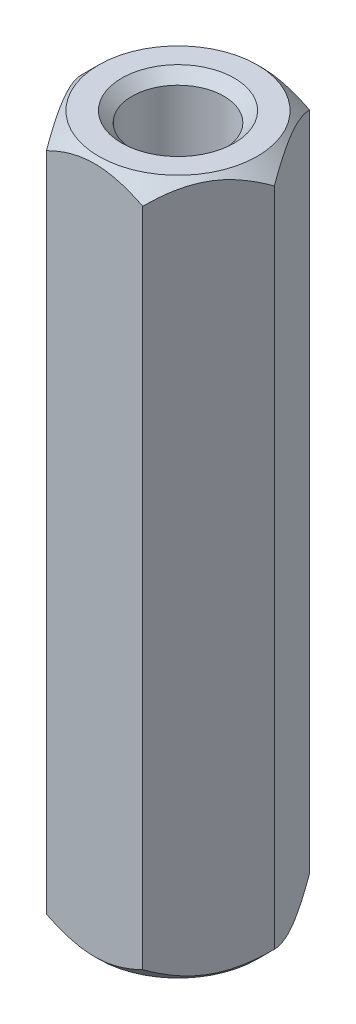
from build123d import *

# Parameters (mm, degrees)
BOSS_EXTRUDE1_DEPTH = 25


with BuildPart() as part:
    # Sketch1 → Boss-Extrude1 (new body)
    with BuildSketch(Plane(origin=(0, 0, 0), x_dir=(1, 0, 0), z_dir=(0, 1, 0))):
        Polygon((1.732050808, 3), (-1.732050808, 3), (-3.464101615, 0), (-1.732050808, -3), (1.732050808, -3), (3.464101615, 0), align=None)
    extrude(amount=BOSS_EXTRUDE1_DEPTH)

    # Sketch2 → M4 Tapped Hole1 (revolve, cut)
    with BuildSketch(Plane(origin=(0, 25, 0), x_dir=(0, 0, 1), z_dir=(1, 0, 0))):
        Polygon((0, 0), (0, 25), (2.025, 25), (1.65, 24.625), (1.65, 0.375), (2.025, 0), align=None)
    revolve(axis=Axis((0, 31.35, 0), (0, -1, 0)), mode=Mode.SUBTRACT)

    # Sketch4 → Cut-Revolve1 (revolve, cut)
    with BuildSketch(Plane.XY):
        Polygon((2.85, 0), (3.464101615, 0.614101615), (3.464101615, 0), align=None)
        Polygon((3.464101615, 25), (2.85, 25), (3.464101615, 24.385898385), align=None)
    revolve(axis=Axis((0, 25, 0), (0, -1, 0)), mode=Mode.SUBTRACT)


solid = part.part
